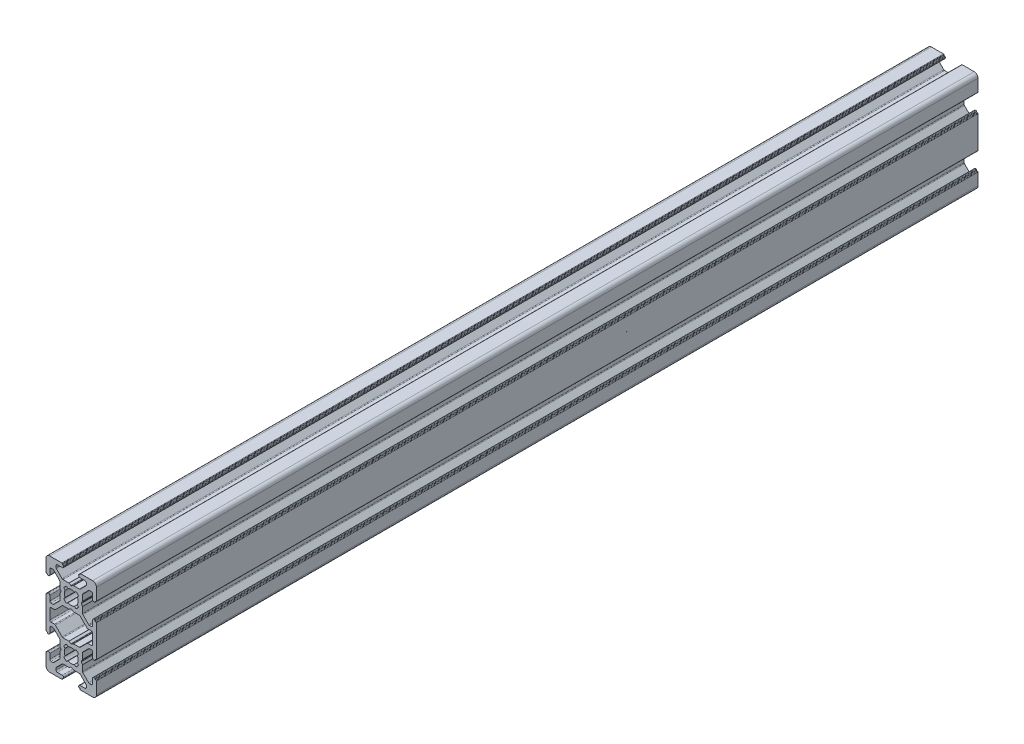
from build123d import *

# Parameters (mm, degrees)
EXTRUDE1_DEPTH = 350


with BuildPart() as part:
    # Sketch1 → Extrude1 (new body)
    with BuildSketch(Plane.XY):
        with BuildLine():
            Line((10, -3.749999824), (10, -8.500000461))
            ThreePointArc((10, -8.500000461), (9.560660307, -9.560660307), (8.500000461, -10))
            Line((8.500000461, -10), (3.699999971, -10))
            ThreePointArc((3.699999971, -10), (3.558578595, -9.941421336), (3.499999971, -9.799999942))
            Line((3.499999971, -9.799999942), (3.5, -9.699999942))
            ThreePointArc((3.5, -9.699999942), (3.441421377, -9.558578549), (3.3, -9.499999885))
            Line((3.3, -9.499999885), (3.2, -9.499999885))
            ThreePointArc((3.2, -9.499999885), (3.058578644, -9.441421241), (3, -9.299999885))
            Line((3, -9.299999885), (3, -9.000001846))
            ThreePointArc((3, -9.000001846), (3.146446609, -8.646448455), (3.5, -8.500001846))
            Line((3.5, -8.500001846), (5.499999866, -8.500001846))
            ThreePointArc((5.499999866, -8.500001846), (5.853553351, -8.353555197), (6, -8.000001712))
            Line((6, -8.000001712), (6, -7.267766328))
            ThreePointArc((6, -7.267766328), (5.961939756, -7.076424587), (5.853553353, -6.914212899))
            Line((5.853553353, -6.914212899), (3.585786596, -4.646446628))
            ThreePointArc((3.585786596, -4.646446628), (3.423574935, -4.53806028), (3.232233243, -4.500000057))
            Line((3.232233243, -4.500000057), (0.953593447, -4.500000057))
            ThreePointArc((0.953593447, -4.500000057), (0.901829637, -4.493185222), (0.853593445, -4.473205136))
            Line((0.853593445, -4.473205136), (0.100000013, -4.038117753))
            ThreePointArc((0.100000013, -4.038117753), (0, -4.011322829), (-0.100000013, -4.038117753))
            Line((-0.100000013, -4.038117753), (-0.853593445, -4.473205136))
            ThreePointArc((-0.853593445, -4.473205136), (-0.901829637, -4.493185222), (-0.953593447, -4.500000057))
            Line((-0.953593447, -4.500000057), (-3.232233243, -4.500000057))
            ThreePointArc((-3.232233243, -4.500000057), (-3.423574935, -4.53806028), (-3.585786596, -4.646446628))
            Line((-3.585786596, -4.646446628), (-5.853553353, -6.914212899))
            ThreePointArc((-5.853553353, -6.914212899), (-5.961939756, -7.076424587), (-6, -7.267766328))
            Line((-6, -7.267766328), (-6, -8.000000007))
            ThreePointArc((-6, -8.000000007), (-5.85355339, -8.353553398), (-5.499999998, -8.500000007))
            Line((-5.499999998, -8.500000007), (-3.500000002, -8.5))
            ThreePointArc((-3.500000002, -8.5), (-3.14644661, -8.646446609), (-3, -9))
            Line((-3, -9), (-3, -9.299998039))
            ThreePointArc((-3, -9.299998039), (-3.058578644, -9.441419395), (-3.2, -9.499998039))
            Line((-3.2, -9.499998039), (-3.3, -9.499998039))
            ThreePointArc((-3.3, -9.499998039), (-3.441421703, -9.558577029), (-3.5, -9.699999019))
            Line((-3.5, -9.699999019), (-3.49999951, -9.799999019))
            ThreePointArc((-3.49999951, -9.799999019), (-3.558577807, -9.94142101), (-3.69999951, -10))
            Line((-3.69999951, -10), (-8.5, -10))
            ThreePointArc((-8.5, -10), (-9.560660172, -9.560660172), (-10, -8.5))
            Line((-10, -8.5), (-10, -3.749999824))
            ThreePointArc((-10, -3.749999824), (-9.941421232, -3.608578344), (-9.799999649, -3.549999824))
            Line((-9.799999649, -3.549999824), (-9.699999649, -3.55))
            ThreePointArc((-9.699999649, -3.55), (-9.558578066, -3.49142148), (-9.499999298, -3.35))
            Line((-9.499999298, -3.35), (-9.499999298, -3.25))
            ThreePointArc((-9.499999298, -3.25), (-9.441420654, -3.108578644), (-9.299999298, -3.05))
            Line((-9.299999298, -3.05), (-8.999999788, -3.05))
            ThreePointArc((-8.999999788, -3.05), (-8.646446398, -3.196446609), (-8.499999788, -3.55))
            Line((-8.499999788, -3.55), (-8.499999788, -5.50000039))
            ThreePointArc((-8.499999788, -5.50000039), (-8.35355314, -5.853553875), (-7.999999654, -6.000000524))
            Line((-7.999999654, -6.000000524), (-7.267766643, -6.000000524))
            ThreePointArc((-7.267766643, -6.000000524), (-7.076424734, -5.96194021), (-6.914212957, -5.853553619))
            Line((-6.914212957, -5.853553619), (-4.646446283, -3.585783155))
            ThreePointArc((-4.646446283, -3.585783155), (-4.538060123, -3.423571583), (-4.499999969, -3.23223006))
            Line((-4.499999969, -3.23223006), (-4.499999969, -0.953590264))
            ThreePointArc((-4.499999969, -0.953590264), (-4.493185135, -0.901826456), (-4.473205051, -0.853590266))
            Line((-4.473205051, -0.853590266), (-4.038119483, -0.099999935))
            ThreePointArc((-4.038119483, -0.099999935), (-4.011324562, 7.7e-08), (-4.038119486, 0.100000089))
            Line((-4.038119486, 0.100000089), (-4.473205047, 0.853590344))
            ThreePointArc((-4.473205047, 0.853590344), (-4.493185134, 0.901826537), (-4.499999969, 0.953590348))
            Line((-4.499999969, 0.953590348), (-4.499999969, 3.232230144))
            ThreePointArc((-4.499999969, 3.232230144), (-4.538060128, 3.423571679), (-4.6464463, 3.585783257))
            Line((-4.6464463, 3.585783257), (-6.914212063, 5.853552589))
            ThreePointArc((-6.914212063, 5.853552589), (-7.076423834, 5.961939167), (-7.267765732, 5.999999476))
            Line((-7.267765732, 5.999999476), (-8.000000569, 5.999999476))
            ThreePointArc((-8.000000569, 5.999999476), (-8.35355396, 5.853552867), (-8.500000569, 5.499999476))
            Line((-8.500000569, 5.499999476), (-8.500000569, 3.45))
            ThreePointArc((-8.500000569, 3.45), (-8.646447179, 3.096446609), (-9.000000569, 2.95))
            Line((-9.000000569, 2.95), (-9.300000079, 2.95))
            ThreePointArc((-9.300000079, 2.95), (-9.441421491, 3.008578699), (-9.500000079, 3.150000158))
            Line((-9.500000079, 3.150000158), (-9.5, 3.250000158))
            ThreePointArc((-9.5, 3.250000158), (-9.558578588, 3.391421616), (-9.7, 3.450000315))
            Line((-9.7, 3.450000315), (-9.8, 3.450000315))
            ThreePointArc((-9.8, 3.450000315), (-9.941421356, 3.508578959), (-10, 3.650000315))
            Line((-10, 3.650000315), (-10, 9.999999757))
            Line((-10, 9.999999757), (-10, 16.3))
            ThreePointArc((-10, 16.3), (-9.941421356, 16.441421356), (-9.8, 16.5))
            Line((-9.8, 16.5), (-9.7, 16.5))
            ThreePointArc((-9.7, 16.5), (-9.558578644, 16.558578644), (-9.5, 16.7))
            Line((-9.5, 16.7), (-9.5, 16.8))
            ThreePointArc((-9.5, 16.8), (-9.441421356, 16.941421356), (-9.3, 17))
            Line((-9.3, 17), (-9.00000049, 17))
            ThreePointArc((-9.00000049, 17), (-8.6464471, 16.853553391), (-8.50000049, 16.5))
            Line((-8.50000049, 16.5), (-8.50000049, 14.55))
            ThreePointArc((-8.50000049, 14.55), (-8.353553881, 14.196446609), (-8.00000049, 14.05))
            Line((-8.00000049, 14.05), (-7.217766334, 14.05))
            ThreePointArc((-7.217766334, 14.05), (-7.026424436, 14.088060309), (-6.864212665, 14.196446888))
            Line((-6.864212665, 14.196446888), (-4.6464463, 16.414216743))
            ThreePointArc((-4.6464463, 16.414216743), (-4.538060128, 16.576428321), (-4.499999969, 16.767769856))
            Line((-4.499999969, 16.767769856), (-4.499999969, 19.046409652))
            ThreePointArc((-4.499999969, 19.046409652), (-4.493185134, 19.098173463), (-4.473205047, 19.146409656))
            Line((-4.473205047, 19.146409656), (-4.038119486, 19.899999911))
            ThreePointArc((-4.038119486, 19.899999911), (-4.011324562, 19.999999923), (-4.038119483, 20.099999935))
            Line((-4.038119483, 20.099999935), (-4.473205051, 20.853590266))
            ThreePointArc((-4.473205051, 20.853590266), (-4.493185135, 20.901826456), (-4.499999969, 20.953590264))
            Line((-4.499999969, 20.953590264), (-4.499999969, 23.23223006))
            ThreePointArc((-4.499999969, 23.23223006), (-4.538060123, 23.423571583), (-4.646446283, 23.585783155))
            Line((-4.646446283, 23.585783155), (-6.96421235, 25.903553095))
            ThreePointArc((-6.96421235, 25.903553095), (-7.126424126, 26.011939686), (-7.317766036, 26.05))
            Line((-7.317766036, 26.05), (-7.999999654, 26.05))
            ThreePointArc((-7.999999654, 26.05), (-8.35355314, 25.903553351), (-8.499999788, 25.549999866))
            Line((-8.499999788, 25.549999866), (-8.499999788, 23.5))
            ThreePointArc((-8.499999788, 23.5), (-8.646446398, 23.146446609), (-8.999999788, 23))
            Line((-8.999999788, 23), (-9.299999298, 23))
            ThreePointArc((-9.299999298, 23), (-9.441420654, 23.058578644), (-9.499999298, 23.2))
            Line((-9.499999298, 23.2), (-9.499999298, 23.3))
            ThreePointArc((-9.499999298, 23.3), (-9.558578066, 23.44142148), (-9.699999649, 23.5))
            Line((-9.699999649, 23.5), (-9.799999649, 23.499999824))
            ThreePointArc((-9.799999649, 23.499999824), (-9.941421232, 23.558578344), (-10, 23.699999824))
            Line((-10, 23.699999824), (-10, 28.5))
            ThreePointArc((-10, 28.5), (-9.560660172, 29.560660172), (-8.5, 30))
            Line((-8.5, 30), (-3.699999511, 30))
            ThreePointArc((-3.699999511, 30), (-3.55857781, 29.941421011), (-3.499999511, 29.799999023))
            Line((-3.499999511, 29.799999023), (-3.5, 29.699999023))
            ThreePointArc((-3.5, 29.699999023), (-3.441421702, 29.558577035), (-3.3, 29.499998046))
            Line((-3.3, 29.499998046), (-3.2, 29.499998046))
            ThreePointArc((-3.2, 29.499998046), (-3.058578644, 29.441419402), (-3, 29.299998046))
            Line((-3, 29.299998046), (-3, 29.000000007))
            ThreePointArc((-3, 29.000000007), (-3.146446609, 28.646446616), (-3.5, 28.500000007))
            Line((-3.5, 28.500000007), (-5.5, 28.500000007))
            ThreePointArc((-5.5, 28.500000007), (-5.853553391, 28.353553397), (-6, 28.000000007))
            Line((-6, 28.000000007), (-6, 27.267766328))
            ThreePointArc((-6, 27.267766328), (-5.961940442, 27.076426242), (-5.853555886, 26.914215433))
            Line((-5.853555886, 26.914215433), (-3.585869751, 24.646497282))
            ThreePointArc((-3.585869751, 24.646497282), (-3.423657211, 24.538109086), (-3.232313865, 24.500048177))
            Line((-3.232313865, 24.500048177), (-0.953674069, 24.500048177))
            ThreePointArc((-0.953674069, 24.500048177), (-0.901910257, 24.493233342), (-0.853674064, 24.473253255))
            Line((-0.853674064, 24.473253255), (-0.100000047, 24.038119334))
            ThreePointArc((-0.100000047, 24.038119334), (-3.5e-08, 24.011324409), (0.099999978, 24.03811933))
            Line((0.099999978, 24.03811933), (0.853674071, 24.473253259))
            ThreePointArc((0.853674071, 24.473253259), (0.901910261, 24.493233342), (0.953674069, 24.500048177))
            Line((0.953674069, 24.500048177), (3.232313865, 24.500048177))
            ThreePointArc((3.232313865, 24.500048177), (3.423657211, 24.538109086), (3.585869751, 24.646497282))
            Line((3.585869751, 24.646497282), (5.853555886, 26.914215433))
            ThreePointArc((5.853555886, 26.914215433), (5.961940442, 27.076426242), (6, 27.267766328))
            Line((6, 27.267766328), (6, 28.000001712))
            ThreePointArc((6, 28.000001712), (5.853553351, 28.353555197), (5.499999866, 28.500001846))
            Line((5.499999866, 28.500001846), (3.5, 28.500001846))
            ThreePointArc((3.5, 28.500001846), (3.146446609, 28.646448455), (3, 29.000001846))
            Line((3, 29.000001846), (3, 29.299999885))
            ThreePointArc((3, 29.299999885), (3.058578562, 29.441421159), (3.199999769, 29.499999885))
            Line((3.199999769, 29.499999885), (3.299999769, 29.5))
            ThreePointArc((3.299999769, 29.5), (3.441420976, 29.558578725), (3.499999539, 29.7))
            Line((3.499999539, 29.7), (3.499999539, 29.8))
            ThreePointArc((3.499999539, 29.8), (3.558578182, 29.941421356), (3.699999539, 30))
            Line((3.699999539, 30), (8.500000027, 30))
            ThreePointArc((8.500000027, 30), (9.56066018, 29.56066018), (10, 28.500000027))
            Line((10, 28.500000027), (10, 23.699999824))
            ThreePointArc((10, 23.699999824), (9.941421232, 23.558578344), (9.799999649, 23.499999824))
            Line((9.799999649, 23.499999824), (9.699999649, 23.5))
            ThreePointArc((9.699999649, 23.5), (9.558578066, 23.44142148), (9.499999298, 23.3))
            Line((9.499999298, 23.3), (9.499999298, 23.2))
            ThreePointArc((9.499999298, 23.2), (9.441420654, 23.058578644), (9.299999298, 23))
            Line((9.299999298, 23), (8.999999788, 23))
            ThreePointArc((8.999999788, 23), (8.646446398, 23.146446609), (8.499999788, 23.5))
            Line((8.499999788, 23.5), (8.499999788, 25.499999261))
            ThreePointArc((8.499999788, 25.499999261), (8.353553179, 25.853552652), (7.999999788, 25.999999261))
            Line((7.999999788, 25.999999261), (7.267765381, 25.999999261))
            ThreePointArc((7.267765381, 25.999999261), (7.076423471, 25.961938948), (6.914211695, 25.853552357))
            Line((6.914211695, 25.853552357), (4.646446283, 23.585783155))
            ThreePointArc((4.646446283, 23.585783155), (4.538060123, 23.423571583), (4.499999969, 23.23223006))
            Line((4.499999969, 23.23223006), (4.499999969, 20.953590264))
            ThreePointArc((4.499999969, 20.953590264), (4.493185135, 20.901826456), (4.473205051, 20.853590266))
            Line((4.473205051, 20.853590266), (4.038119525, 20.100000009))
            ThreePointArc((4.038119525, 20.100000009), (4.011324604, 20.000000005), (4.03811952, 19.899999999))
            Line((4.03811952, 19.899999999), (4.473205056, 19.146409641))
            ThreePointArc((4.473205056, 19.146409641), (4.493185136, 19.098173455), (4.499999969, 19.046409652))
            Line((4.499999969, 19.046409652), (4.499999969, 16.767769856))
            ThreePointArc((4.499999969, 16.767769856), (4.538060128, 16.576428321), (4.6464463, 16.414216743))
            Line((4.6464463, 16.414216743), (6.914213325, 14.146446149))
            ThreePointArc((6.914213325, 14.146446149), (7.076425096, 14.03805957), (7.267766994, 13.999999261))
            Line((7.267766994, 13.999999261), (7.999999654, 13.999999261))
            ThreePointArc((7.999999654, 13.999999261), (8.35355314, 14.14644591), (8.499999788, 14.499999395))
            Line((8.499999788, 14.499999395), (8.499999788, 16.5))
            ThreePointArc((8.499999788, 16.5), (8.646446398, 16.853553391), (8.999999788, 17))
            Line((8.999999788, 17), (9.299999298, 17))
            ThreePointArc((9.299999298, 17), (9.441420654, 16.941421356), (9.499999298, 16.8))
            Line((9.499999298, 16.8), (9.499999298, 16.7))
            ThreePointArc((9.499999298, 16.7), (9.558578066, 16.55857852), (9.699999649, 16.5))
            Line((9.699999649, 16.5), (9.799999649, 16.500000176))
            ThreePointArc((9.799999649, 16.500000176), (9.941421232, 16.441421656), (10, 16.300000176))
            Line((10, 16.300000176), (10, 10))
            Line((10, 10), (10, 3.650000315))
            ThreePointArc((10, 3.650000315), (9.941421356, 3.508578959), (9.8, 3.450000315))
            Line((9.8, 3.450000315), (9.7, 3.450000315))
            ThreePointArc((9.7, 3.450000315), (9.558578588, 3.391421616), (9.5, 3.250000158))
            Line((9.5, 3.250000158), (9.500000079, 3.150000158))
            ThreePointArc((9.500000079, 3.150000158), (9.441421491, 3.0085787), (9.300000079, 2.95))
            Line((9.300000079, 2.95), (9.000000569, 2.95))
            ThreePointArc((9.000000569, 2.95), (8.646447179, 3.096446609), (8.500000569, 3.45))
            Line((8.500000569, 3.45), (8.500000569, 5.499999342))
            ThreePointArc((8.500000569, 5.499999342), (8.353553921, 5.853552828), (8.000000435, 5.999999476))
            Line((8.000000435, 5.999999476), (7.267765732, 5.999999476))
            ThreePointArc((7.267765732, 5.999999476), (7.076423834, 5.961939167), (6.914212063, 5.853552589))
            Line((6.914212063, 5.853552589), (4.6464463, 3.585783257))
            ThreePointArc((4.6464463, 3.585783257), (4.538060128, 3.423571679), (4.499999969, 3.232230144))
            Line((4.499999969, 3.232230144), (4.499999969, 0.953590348))
            ThreePointArc((4.499999969, 0.953590348), (4.493185136, 0.901826545), (4.473205056, 0.853590359))
            Line((4.473205056, 0.853590359), (4.03811952, 0.100000001))
            ThreePointArc((4.03811952, 0.100000001), (4.011324604, -5e-09), (4.038119525, -0.100000009))
            Line((4.038119525, -0.100000009), (4.473205051, -0.853590266))
            ThreePointArc((4.473205051, -0.853590266), (4.493185135, -0.901826456), (4.499999969, -0.953590264))
            Line((4.499999969, -0.953590264), (4.499999969, -3.23223006))
            ThreePointArc((4.499999969, -3.23223006), (4.538060123, -3.423571583), (4.646446283, -3.585783155))
            Line((4.646446283, -3.585783155), (6.914212957, -5.853553619))
            ThreePointArc((6.914212957, -5.853553619), (7.076424734, -5.96194021), (7.267766643, -6.000000524))
            Line((7.267766643, -6.000000524), (7.999999788, -6.000000524))
            ThreePointArc((7.999999788, -6.000000524), (8.353553179, -5.853553914), (8.499999788, -5.500000524))
            Line((8.499999788, -5.500000524), (8.499999788, -3.55))
            ThreePointArc((8.499999788, -3.55), (8.646446398, -3.196446609), (8.999999788, -3.05))
            Line((8.999999788, -3.05), (9.299999298, -3.05))
            ThreePointArc((9.299999298, -3.05), (9.441420654, -3.108578644), (9.499999298, -3.25))
            Line((9.499999298, -3.25), (9.499999298, -3.35))
            ThreePointArc((9.499999298, -3.35), (9.558578066, -3.49142148), (9.699999649, -3.55))
            Line((9.699999649, -3.55), (9.799999649, -3.549999824))
            ThreePointArc((9.799999649, -3.549999824), (9.941421232, -3.608578344), (10, -3.749999824))
        make_face()
        with BuildLine():
            Line((2.445295362, 18.741814564), (2.947714945, 18.112944992))
            ThreePointArc((2.947714945, 18.112944992), (2.474873674, 17.525126206), (1.887054865, 17.052284963))
            Line((1.887054865, 17.052284963), (1.258185317, 17.554704577))
            ThreePointArc((1.258185317, 17.554704577), (-6.7e-08, 17.25), (-1.258185436, 17.554704638))
            Line((-1.258185436, 17.554704638), (-1.887055008, 17.052285055))
            ThreePointArc((-1.887055008, 17.052285055), (-2.474873794, 17.525126326), (-2.947715037, 18.112945135))
            Line((-2.947715037, 18.112945135), (-2.445295423, 18.741814683))
            ThreePointArc((-2.445295423, 18.741814683), (-2.75, 20.000000067), (-2.445295362, 21.258185436))
            Line((-2.445295362, 21.258185436), (-2.947714945, 21.887055008))
            ThreePointArc((-2.947714945, 21.887055008), (-2.474873674, 22.474873794), (-1.887054865, 22.947715037))
            Line((-1.887054865, 22.947715037), (-1.258185317, 22.445295423))
            ThreePointArc((-1.258185317, 22.445295423), (6.7e-08, 22.75), (1.258185436, 22.445295362))
            Line((1.258185436, 22.445295362), (1.887055008, 22.947714945))
            ThreePointArc((1.887055008, 22.947714945), (2.474873794, 22.474873674), (2.947715037, 21.887054865))
            Line((2.947715037, 21.887054865), (2.445295423, 21.258185317))
            ThreePointArc((2.445295423, 21.258185317), (2.75, 19.999999933), (2.445295362, 18.741814564))
        make_face(mode=Mode.SUBTRACT)
        with BuildLine():
            Line((3.232248767, 15.499989219), (0.953608971, 15.499989219))
            ThreePointArc((0.953608971, 15.499989219), (0.90184516, 15.506804055), (0.853608967, 15.526784141))
            Line((0.853608967, 15.526784141), (0.100000047, 15.961880478))
            ThreePointArc((0.100000047, 15.961880478), (3.5e-08, 15.988675403), (-0.099999978, 15.961880482))
            Line((-0.099999978, 15.961880482), (-0.853608973, 15.526784137))
            ThreePointArc((-0.853608973, 15.526784137), (-0.901845163, 15.506804054), (-0.953608971, 15.499989219))
            Line((-0.953608971, 15.499989219), (-3.232248767, 15.499989219))
            ThreePointArc((-3.232248767, 15.499989219), (-3.42359066, 15.461928912), (-3.585802428, 15.35354234))
            Line((-3.585802428, 15.35354234), (-6.292893753, 12.646446879))
            ThreePointArc((-6.292893753, 12.646446879), (-6.455105521, 12.538060307), (-6.646447414, 12.5))
            Line((-6.646447414, 12.5), (-7.999999788, 12.5))
            ThreePointArc((-7.999999788, 12.5), (-8.353553179, 12.353553391), (-8.499999788, 12))
            Line((-8.499999788, 12), (-8.499999788, 8))
            ThreePointArc((-8.499999788, 8), (-8.353553179, 7.646446609), (-7.999999788, 7.5))
            Line((-7.999999788, 7.5), (-6.646447414, 7.5))
            ThreePointArc((-6.646447414, 7.5), (-6.455102332, 7.461938372), (-6.292888871, 7.353548238))
            Line((-6.292888871, 7.353548238), (-3.585984195, 4.646564667))
            ThreePointArc((-3.585984195, 4.646564667), (-3.423770734, 4.538174533), (-3.232425652, 4.500112905))
            Line((-3.232425652, 4.500112905), (-0.953785856, 4.500112905))
            ThreePointArc((-0.953785856, 4.500112905), (-0.902022048, 4.493298071), (-0.853785858, 4.473317987))
            Line((-0.853785858, 4.473317987), (-0.099999978, 4.038119518))
            ThreePointArc((-0.099999978, 4.038119518), (3.5e-08, 4.011324597), (0.100000047, 4.038119522))
            Line((0.100000047, 4.038119522), (0.853785852, 4.473317984))
            ThreePointArc((0.853785852, 4.473317984), (0.902022045, 4.49329807), (0.953785856, 4.500112905))
            Line((0.953785856, 4.500112905), (3.232425652, 4.500112905))
            ThreePointArc((3.232425652, 4.500112905), (3.423770734, 4.538174533), (3.585984195, 4.646564667))
            Line((3.585984195, 4.646564667), (6.292888591, 7.353547959))
            ThreePointArc((6.292888591, 7.353547959), (6.455102052, 7.461938093), (6.646447134, 7.49999972))
            Line((6.646447134, 7.49999972), (7.999999788, 7.49999972))
            ThreePointArc((7.999999788, 7.49999972), (8.353553179, 7.64644633), (8.499999788, 7.99999972))
            Line((8.499999788, 7.99999972), (8.499999788, 12.000000281))
            ThreePointArc((8.499999788, 12.000000281), (8.353553179, 12.353553672), (7.999999788, 12.500000281))
            Line((7.999999788, 12.500000281), (6.646447132, 12.500000281))
            ThreePointArc((6.646447132, 12.500000281), (6.45510524, 12.538060588), (6.292893472, 12.646447161))
            Line((6.292893472, 12.646447161), (3.585802428, 15.35354234))
            ThreePointArc((3.585802428, 15.35354234), (3.42359066, 15.461928912), (3.232248767, 15.499989219))
        make_face(mode=Mode.SUBTRACT)
        with BuildLine():
            Line((1.258185436, -2.445295362), (1.887055008, -2.947714945))
            ThreePointArc((1.887055008, -2.947714945), (2.474873794, -2.474873674), (2.947715037, -1.887054865))
            Line((2.947715037, -1.887054865), (2.445295423, -1.258185317))
            ThreePointArc((2.445295423, -1.258185317), (2.75, 6.7e-08), (2.445295362, 1.258185436))
            Line((2.445295362, 1.258185436), (2.947714945, 1.887055008))
            ThreePointArc((2.947714945, 1.887055008), (2.474873674, 2.474873794), (1.887054865, 2.947715037))
            Line((1.887054865, 2.947715037), (1.258185317, 2.445295423))
            ThreePointArc((1.258185317, 2.445295423), (-6.7e-08, 2.75), (-1.258185436, 2.445295362))
            Line((-1.258185436, 2.445295362), (-1.887055008, 2.947714945))
            ThreePointArc((-1.887055008, 2.947714945), (-2.474873794, 2.474873674), (-2.947715037, 1.887054865))
            Line((-2.947715037, 1.887054865), (-2.445295423, 1.258185317))
            ThreePointArc((-2.445295423, 1.258185317), (-2.75, -6.7e-08), (-2.445295362, -1.258185436))
            Line((-2.445295362, -1.258185436), (-2.947714945, -1.887055008))
            ThreePointArc((-2.947714945, -1.887055008), (-2.474873674, -2.474873794), (-1.887054865, -2.947715037))
            Line((-1.887054865, -2.947715037), (-1.258185317, -2.445295423))
            ThreePointArc((-1.258185317, -2.445295423), (6.7e-08, -2.75), (1.258185436, -2.445295362))
        make_face(mode=Mode.SUBTRACT)
    extrude(amount=EXTRUDE1_DEPTH)


solid = part.part
